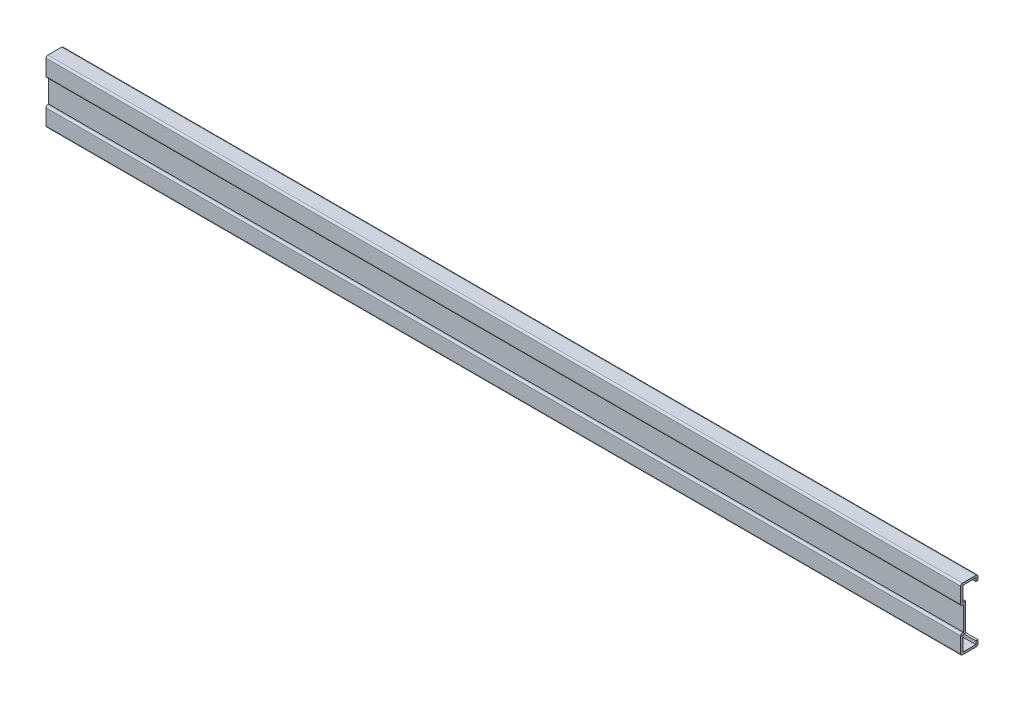
from build123d import *

# Parameters (mm, degrees)
EXTRUDE_3_DEPTH = 500


with BuildPart() as part:
    # Эскиз1 → Вытянуть-Тонкостенный3 (new body)
    with BuildSketch(Plane(origin=(0, 0, 0), x_dir=(0, 0, -1), z_dir=(1, 0, 0))):
        with BuildLine():
            Line((8, 14), (8, 16))
            ThreePointArc((8, 16), (7.707106781, 16.707106781), (7, 17))
            Line((7, 17), (-0.5, 17))
            ThreePointArc((-0.5, 17), (-1.207106781, 16.707106781), (-1.5, 16))
            Line((-1.5, 16), (-1.5, 7.5))
            ThreePointArc((-1.5, 7.5), (-1.207106781, 6.792893219), (-0.5, 6.5))
            Line((-0.5, 6.5), (0, 6.5))
            Line((0, 6.5), (0, -6.5))
            Line((0, -6.5), (-0.5, -6.5))
            ThreePointArc((-0.5, -6.5), (-1.207106781, -6.792893219), (-1.5, -7.5))
            Line((-1.5, -7.5), (-1.5, -16))
            ThreePointArc((-1.5, -16), (-1.207106781, -16.707106781), (-0.5, -17))
            Line((-0.5, -17), (7, -17))
            ThreePointArc((7, -17), (7.707106781, -16.707106781), (8, -16))
            Line((8, -16), (8, -14))
            Line((8, -14), (6.8, -14))
            Line((6.8, -14), (6.8, -15.8))
            Line((6.8, -15.8), (-0.3, -15.8))
            Line((-0.3, -15.8), (-0.3, -7.7))
            Line((-0.3, -7.7), (1.2, -7.7))
            Line((1.2, -7.7), (1.2, 7.7))
            Line((1.2, 7.7), (-0.3, 7.7))
            Line((-0.3, 7.7), (-0.3, 15.8))
            Line((-0.3, 15.8), (6.8, 15.8))
            Line((6.8, 15.8), (6.8, 14))
            Line((6.8, 14), (8, 14))
        make_face()
    extrude(amount=EXTRUDE_3_DEPTH)


solid = part.part
